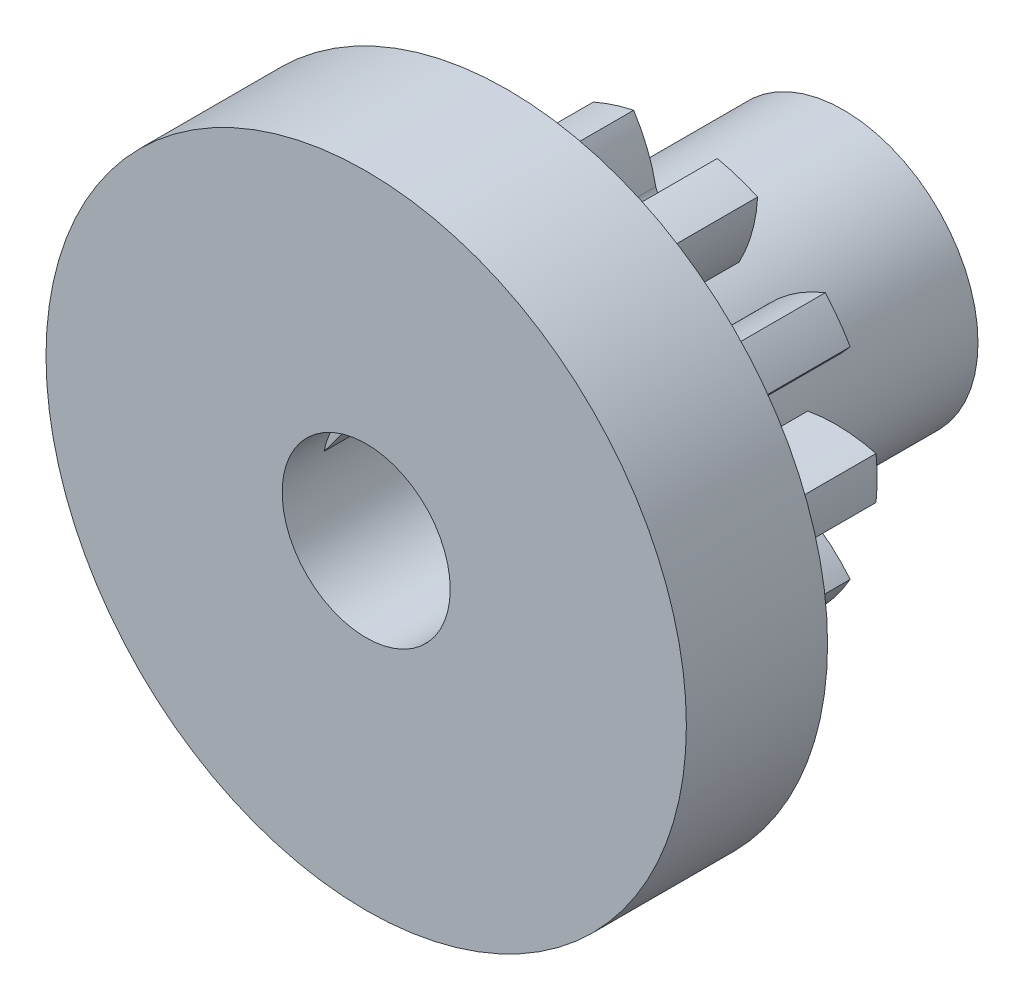
from build123d import *

# Parameters (mm, degrees)
SKETCH2_R           = 12
BOSS_EXTRUDE1_DEPTH = 10
CUT_EXTRUDE1_DEPTH  = 21
FILLET1_R           = 0.6
SKETCH4_R           = 19.05
BOSS_EXTRUDE2_DEPTH = 8.4
CIRPATTERN1_COUNT   = 10
SKETCH5_R           = 5
CUT_EXTRUDE2_DEPTH  = 2.4
CUT_EXTRUDE3_DEPTH  = 20
SKETCH7_R           = 12
SKETCH7_R_2         = 8
CUT_EXTRUDE4_DEPTH  = 10


with BuildPart() as part:
    # Sketch2 → Boss-Extrude1 (new body, symmetric)
    with BuildSketch(Plane.XY):
        Circle(SKETCH2_R)
    extrude(amount=BOSS_EXTRUDE1_DEPTH, both=True)

    # Sketch3 → Cut-Extrude1 (cut, through all)
    with BuildSketch(Plane.XY.offset(10)):
        with BuildLine():
            ThreePointArc((1.082135592, 7.926473526), (0, 8), (-1.082135592, 7.926473526))
            ThreePointArc((-1.082135592, 7.926473526), (-1.576305236, 9.909557234), (-2.485975838, 11.739673085))
            ThreePointArc((-2.485975838, 11.739673085), (0, 12), (2.485975838, 11.739673085))
            ThreePointArc((2.485975838, 11.739673085), (1.576305236, 9.909557234), (1.082135592, 7.926473526))
        make_face()
    cut_extrude1 = extrude(amount=-CUT_EXTRUDE1_DEPTH, mode=Mode.SUBTRACT)

    # Fillet1
    fillet1_edges = [part.edges().sort_by_distance(p)[0] for p in [
        (1.082135592, 7.926473526, 0),
        (-1.082135592, 7.926473526, 0),
    ]]
    fillet(fillet1_edges, radius=FILLET1_R)

    # Sketch4 → Boss-Extrude2 (add)
    with BuildSketch(Plane.XY.offset(10)):
        Circle(SKETCH4_R)
    extrude(amount=BOSS_EXTRUDE2_DEPTH)

    # CirPattern1: Cut-Extrude1 ×10 about axis
    cirpattern1_axis = Axis((0, 0, 0), (0, 0, 1))
    for i in range(1, CIRPATTERN1_COUNT):
        add(cut_extrude1.rotate(cirpattern1_axis, i * 360 / CIRPATTERN1_COUNT), mode=Mode.SUBTRACT)

    # Sketch5 → Cut-Extrude2 (cut)
    with BuildSketch(Plane.XY.offset(18.4)):
        Circle(SKETCH5_R)
    extrude(amount=-CUT_EXTRUDE2_DEPTH, mode=Mode.SUBTRACT)

    # Sketch6 → Cut-Extrude3 (cut)
    with BuildSketch(Plane.XY.offset(16)):
        with BuildLine():
            Line((-4.908635362, 0.951471955), (-2.296829324, 4.441235758))
            ThreePointArc((-2.296829324, 4.441235758), (4.003035497, -2.9959484), (-4.908635362, 0.951471955))
        make_face()
    extrude(amount=-CUT_EXTRUDE3_DEPTH, mode=Mode.SUBTRACT)

    # Sketch7 → Cut-Extrude4 (cut)
    with BuildSketch(Plane(origin=(0, 0, -10), x_dir=(-1, 0, 0), z_dir=(0, 0, -1))):
        Circle(SKETCH7_R)
        Circle(SKETCH7_R_2, mode=Mode.SUBTRACT)
    extrude(amount=-CUT_EXTRUDE4_DEPTH, mode=Mode.SUBTRACT)


solid = part.part
